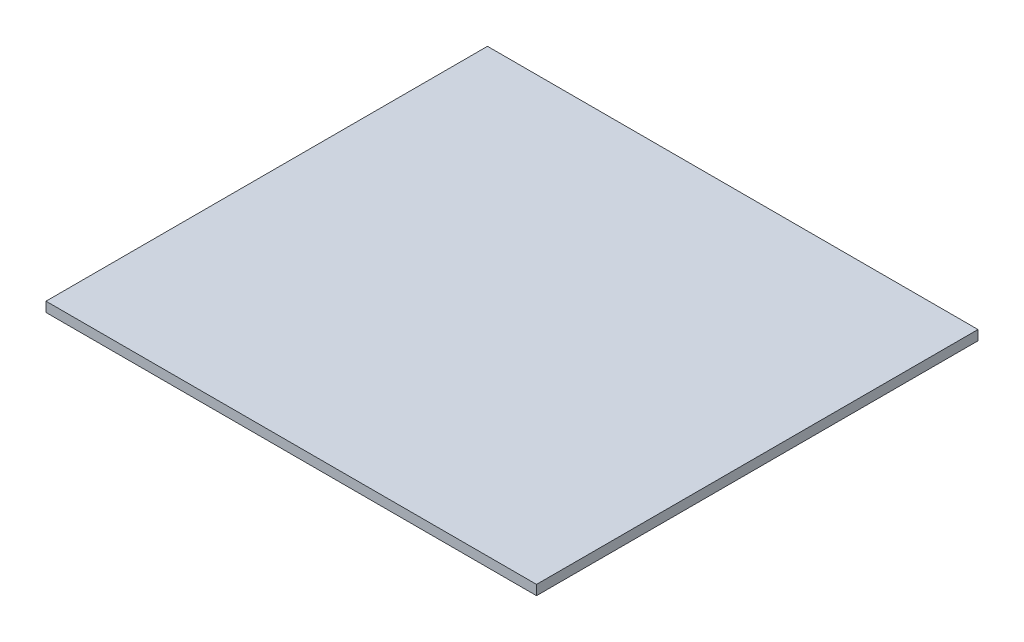
from build123d import *

# Parameters (mm, degrees)
SKETCH1_W           = 254
SKETCH1_H           = 228.6
BOSS_EXTRUDE1_DEPTH = 5.08


with BuildPart() as part:
    # Sketch1 → Boss-Extrude1 (new body)
    with BuildSketch(Plane(origin=(0, 0, 0), x_dir=(1, 0, 0), z_dir=(0, 1, 0))):
        with Locations((127, 114.3)):
            Rectangle(SKETCH1_W, SKETCH1_H)
    extrude(amount=BOSS_EXTRUDE1_DEPTH)


solid = part.part
